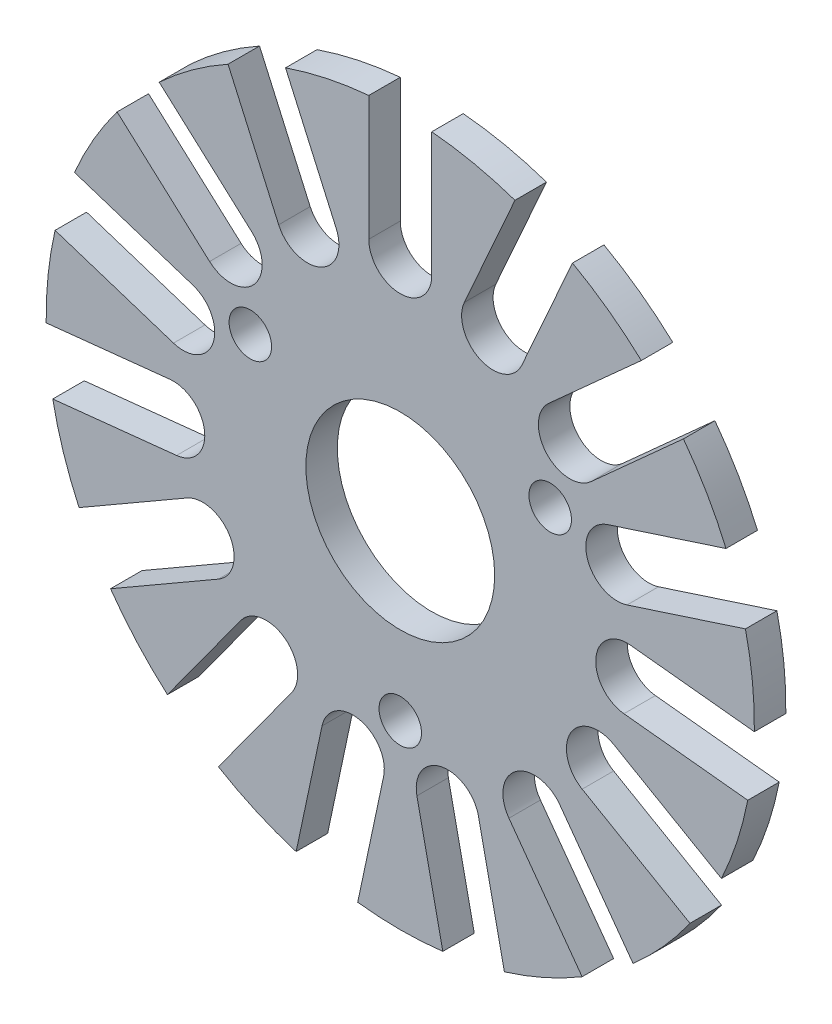
from build123d import *

# Parameters (mm, degrees)
SKETCH1_R           = 1.35
SKETCH1_R_2         = 6
BOSS_EXTRUDE1_DEPTH = 2


with BuildPart() as part:
    # Sketch1 → Boss-Extrude1 (new body)
    with BuildSketch(Plane(origin=(0, 0, 0), x_dir=(-1, 0, 0), z_dir=(0, 0, -1))):
        with BuildLine():
            Line((-15.316309042, 17.102154929), (-9.437338757, 11.808706309))
            ThreePointArc((-9.437338757, 11.808706309), (-9.289310319, 8.984155445), (-12.113861182, 8.836127007))
            Line((-12.113861182, 8.836127007), (-17.992831467, 14.129575627))
            ThreePointArc((-17.992831467, 14.129575627), (-19.485571585, 11.870022867), (-20.696031618, 9.447495623))
            Line((-20.696031618, 9.447495623), (-13.172285497, 7.002882316))
            ThreePointArc((-13.172285497, 7.002882316), (-11.888206454, 4.482735294), (-14.408353475, 3.198656251))
            Line((-14.408353475, 3.198656251), (-21.932099596, 5.643269556))
            ThreePointArc((-21.932099596, 5.643269556), (-22.376742646, 2.971913289), (-22.497222312, 0.266486078))
            Line((-22.497222312, 0.266486078), (-14.62962441, 1.093403939))
            ThreePointArc((-14.62962441, 1.093403939), (-12.431523692, -0.686582926), (-14.211510557, -2.884683643))
            Line((-14.211510557, -2.884683643), (-22.079108459, -3.711601503))
            ThreePointArc((-22.079108459, -3.711601503), (-21.398771617, -6.332859507), (-20.408438887, -8.853393742))
            Line((-20.408438887, -8.853393742), (-13.557368355, -4.897926326))
            ThreePointArc((-13.557368355, -4.897926326), (-10.825317547, -5.629977134), (-11.557368355, -8.362027942))
            Line((-11.557368355, -8.362027942), (-18.408438886, -12.317495358))
            ThreePointArc((-18.408438886, -12.317495358), (-16.720758571, -14.435415779), (-14.790850969, -16.335233771))
            Line((-14.790850969, -16.335233771), (-10.140920148, -9.935153049))
            ThreePointArc((-10.140920148, -9.935153049), (-7.347315654, -9.492689564), (-6.90485217, -12.286294058))
            Line((-6.90485217, -12.286294058), (-11.554782995, -18.686374777))
            ThreePointArc((-11.554782995, -18.686374777), (-9.151574469, -19.934749931), (-6.615790555, -20.885355888))
            Line((-6.615790555, -20.885355888), (-4.971014718, -13.147293963))
            ThreePointArc((-4.971014718, -13.147293963), (-2.598896135, -11.606822144), (-1.058424316, -13.978940727))
            Line((-1.058424316, -13.978940727), (-2.703200152, -21.717002651))
            ThreePointArc((-2.703200152, -21.717002651), (-3e-09, -21.879977134), (2.703200146, -21.717002651))
            Line((2.703200146, -21.717002651), (1.058424314, -13.978940725))
            ThreePointArc((1.058424314, -13.978940725), (2.598896135, -11.606822143), (4.971014718, -13.147293963))
            Line((4.971014718, -13.147293963), (6.615790554, -20.885355888))
            ThreePointArc((6.615790554, -20.885355888), (9.151574469, -19.934749931), (11.554782995, -18.686374777))
            Line((11.554782995, -18.686374777), (6.904852169, -12.286294058))
            ThreePointArc((6.904852169, -12.286294058), (7.347315653, -9.492689564), (10.140920146, -9.935153048))
            Line((10.140920146, -9.935153048), (14.790850972, -16.335233768))
            ThreePointArc((14.790850972, -16.335233768), (16.720758571, -14.435415779), (18.408438883, -12.317495361))
            Line((18.408438883, -12.317495361), (11.557368352, -8.362027946))
            ThreePointArc((11.557368352, -8.362027946), (10.825317543, -5.629977135), (13.557368354, -4.897926327))
            Line((13.557368354, -4.897926327), (20.408438886, -8.853393742))
            ThreePointArc((20.408438886, -8.853393742), (21.398771616, -6.332859507), (22.079108458, -3.711601502))
            Line((22.079108458, -3.711601502), (14.211510556, -2.884683643))
            ThreePointArc((14.211510556, -2.884683643), (12.431523691, -0.686582926), (14.629624409, 1.093403939))
            Line((14.629624409, 1.093403939), (22.497222311, 0.266486078))
            ThreePointArc((22.497222311, 0.266486078), (22.376742645, 2.971913287), (21.932099596, 5.643269552))
            Line((21.932099596, 5.643269552), (14.408353473, 3.19865625))
            ThreePointArc((14.408353473, 3.19865625), (11.888206452, 4.482735295), (13.172285497, 7.002882316))
            Line((13.172285497, 7.002882316), (20.696031618, 9.447495621))
            ThreePointArc((20.696031618, 9.447495621), (19.485571584, 11.870022866), (17.992831465, 14.129575628))
            Line((17.992831465, 14.129575628), (12.113861182, 8.836127007))
            ThreePointArc((12.113861182, 8.836127007), (9.289310318, 8.984155445), (9.437338756, 11.808706308))
            Line((9.437338756, 11.808706308), (15.316309041, 17.102154929))
            ThreePointArc((15.316309041, 17.102154929), (13.225168178, 18.822905238), (10.94243932, 20.279957294))
            Line((10.94243932, 20.279957294), (7.724772239, 13.052958714))
            ThreePointArc((7.724772239, 13.052958714), (5.084208037, 12.039341086), (4.070590408, 14.679905287))
            Line((4.070590408, 14.679905287), (7.288257486, 21.906903868))
            ThreePointArc((7.288257486, 21.906903868), (4.67801304, 22.628343883), (1.999999993, 23.030957697))
            Line((1.999999993, 23.030957697), (1.999999993, 15.120022866))
            ThreePointArc((1.999999993, 15.120022866), (-1e-09, 13.120022872), (-1.999999995, 15.120022866))
            Line((-1.999999995, 15.120022866), (-1.999999995, 23.030957697))
            ThreePointArc((-1.999999995, 23.030957697), (-4.67801304, 22.628343883), (-7.288257483, 21.906903869))
            Line((-7.288257483, 21.906903869), (-4.070590409, 14.679905287))
            ThreePointArc((-4.070590409, 14.679905287), (-5.084208039, 12.039341085), (-7.72477224, 13.052958715))
            Line((-7.72477224, 13.052958715), (-10.942439317, 20.279957296))
            ThreePointArc((-10.942439317, 20.279957296), (-13.225168177, 18.822905239), (-15.316309042, 17.102154929))
        make_face()
        with Locations((9.526279442, 6.120022866)):
            Circle(SKETCH1_R, mode=Mode.SUBTRACT)
        with Locations((-9.526279442, 6.120022866)):
            Circle(SKETCH1_R, mode=Mode.SUBTRACT)
        with Locations((0, -10.379977134)):
            Circle(SKETCH1_R, mode=Mode.SUBTRACT)
        with Locations((0, 0.620022866)):
            Circle(SKETCH1_R_2, mode=Mode.SUBTRACT)
    extrude(amount=-BOSS_EXTRUDE1_DEPTH)


solid = part.part
